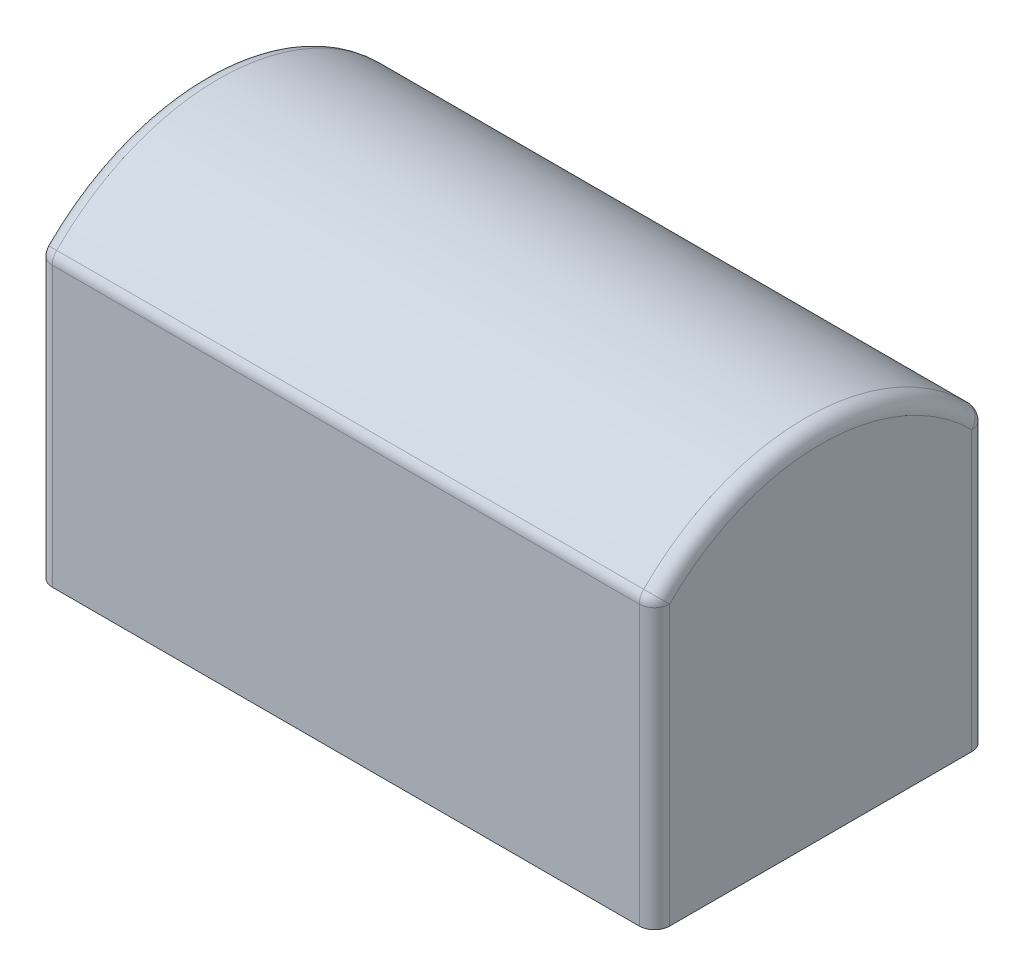
from build123d import *

# Parameters (mm, degrees)
BOSS_EXTRUDE1_DEPTH = 10.31875
FILLET1_R           = 0.254


with BuildPart() as part:
    # Sketch1 → Boss-Extrude1 (new body)
    with BuildSketch(Plane(origin=(0, 0, 0), x_dir=(0, 0, -1), z_dir=(1, 0, 0))):
        with BuildLine():
            Line((-2.778125, 0), (2.778125, 0))
            Line((2.778125, 0), (2.778125, 4.7625))
            ThreePointArc((2.778125, 4.7625), (0, 5.966386343), (-2.778125, 4.7625))
            Line((-2.778125, 4.7625), (-2.778125, 0))
        make_face()
    extrude(amount=BOSS_EXTRUDE1_DEPTH)

    # Fillet1
    fillet1_edges = [part.edges().sort_by_distance(p)[0] for p in [
        (10.31875, 2.38125, 2.778125),
        (10.31875, 2.38125, -2.778125),
        (0, 2.38125, 2.778125),
        (0, 5.966386343, 0),
        (0, 2.38125, -2.778125),
        (5.159375, 4.7625, 2.778125),
        (5.159375, 4.7625, -2.778125),
        (10.31875, 5.966386343, 0),
    ]]
    fillet(fillet1_edges, radius=FILLET1_R)


solid = part.part
